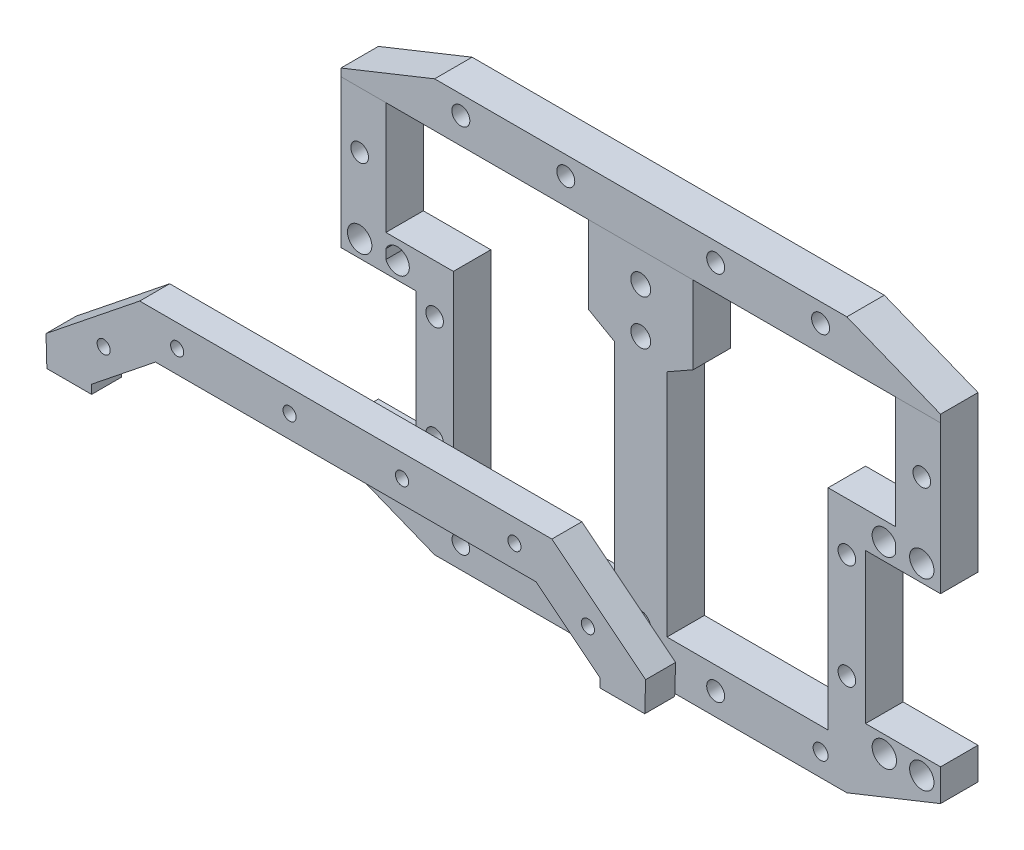
from build123d import *

# Parameters (mm, degrees)
SKETCH1_R           = 2.399612855
SKETCH1_R_2         = 2.65
SKETCH1_R_3         = 2.350999085
SKETCH1_R_4         = 3.25
SKETCH1_R_5         = 2.35
SKETCH1_R_6         = 2
SKETCH1_R_7         = 2.477632292
SKETCH1_R_8         = 2.354161753
BOSS_EXTRUDE1_DEPTH = 10
SKETCH2_R           = 6
SKETCH2_R_2         = 1.75
BOSS_EXTRUDE2_DEPTH = 8
SKETCH3_W           = 243.313173006
SKETCH3_H           = 81.330853515
CUT_EXTRUDE1_DEPTH  = 8
CUT_EXTRUDE2_DEPTH  = 8


with BuildPart() as part:
    # Sketch1 → Boss-Extrude1 (new body)
    with BuildSketch(Plane.XY):
        Polygon((80, -36.5), (60, -36.5), (60, 3.5), (80, 3.5), (80, 45), (55, 55), (-55, 55), (-80, 45), (-80, 3.5), (-60, 3.5), (-60, -36.5), (-80, -36.5), (-80, -45), (-55, -55), (55, -55), (80, -45), align=None)
        with Locations((-48, 50)):
            Circle(SKETCH1_R, mode=Mode.SUBTRACT)
        with Locations((-20, 50)):
            Circle(SKETCH1_R, mode=Mode.SUBTRACT)
        with Locations((0, 35)):
            Circle(SKETCH1_R_2, mode=Mode.SUBTRACT)
        with Locations((0, 23)):
            Circle(SKETCH1_R_2, mode=Mode.SUBTRACT)
        with Locations((20, 50)):
            Circle(SKETCH1_R, mode=Mode.SUBTRACT)
        with Locations((48, 50)):
            Circle(SKETCH1_R, mode=Mode.SUBTRACT)
        with Locations((75, 28)):
            Circle(SKETCH1_R_3, mode=Mode.SUBTRACT)
        with Locations((75, 8)):
            Circle(SKETCH1_R_4, mode=Mode.SUBTRACT)
        with Locations((55, 0)):
            Circle(SKETCH1_R_5, mode=Mode.SUBTRACT)
        with Locations((55, -28)):
            Circle(SKETCH1_R_5, mode=Mode.SUBTRACT)
        with Locations((75, -41)):
            Circle(SKETCH1_R_4, mode=Mode.SUBTRACT)
        with Locations((65, -41)):
            Circle(SKETCH1_R_4, mode=Mode.SUBTRACT)
        with Locations((48, -49)):
            Circle(SKETCH1_R_6, mode=Mode.SUBTRACT)
        with Locations((20, -49)):
            Circle(SKETCH1_R, mode=Mode.SUBTRACT)
        with Locations((0, -43)):
            Circle(SKETCH1_R_2, mode=Mode.SUBTRACT)
        with Locations((-20, -49)):
            Circle(SKETCH1_R_7, mode=Mode.SUBTRACT)
        with Locations((-48, -49)):
            Circle(SKETCH1_R_8, mode=Mode.SUBTRACT)
        with Locations((-75, -41)):
            Circle(SKETCH1_R_4, mode=Mode.SUBTRACT)
        with Locations((-65, -41)):
            Circle(SKETCH1_R_4, mode=Mode.SUBTRACT)
        with Locations((-55, -28)):
            Circle(SKETCH1_R_5, mode=Mode.SUBTRACT)
        with Locations((-55, 0)):
            Circle(SKETCH1_R_5, mode=Mode.SUBTRACT)
        with Locations((-75, 8)):
            Circle(SKETCH1_R_4, mode=Mode.SUBTRACT)
        with Locations((-75, 28)):
            Circle(SKETCH1_R_3, mode=Mode.SUBTRACT)
        with BuildLine():
            Line((68, 6.75), (68, 9.25))
            ThreePointArc((68, 9.25), (61.75, 8), (68, 6.75))
        make_face(mode=Mode.SUBTRACT)
        with BuildLine():
            Line((-68, 6.75), (-68, 9.25))
            ThreePointArc((-68, 9.25), (-61.75, 8), (-68, 6.75))
        make_face(mode=Mode.SUBTRACT)
        Polygon((-50, 13), (-68, 13), (-68, 43), (-14, 43), (-14, 22.26503624), (-7, 18.293621962), (-7, -43), (-50, -43), align=None, mode=Mode.SUBTRACT)
        Polygon((50, -43), (7, -43), (7, 18.293621962), (14, 22.26503624), (14, 43), (68, 43), (68, 13), (50, 13), align=None, mode=Mode.SUBTRACT)
    extrude(amount=BOSS_EXTRUDE1_DEPTH)


with BuildPart() as body_2:
    # Sketch2 → Boss-Extrude2 (new body)
    with BuildSketch(Plane.XY.offset(88.7)):
        Polygon((-80, 22.996033378), (-55, 42.996033378), (55, 42.996033378), (80, 22.996033378), (77.932657225, -48.34767687), (70, -55.003966622), (-70, -55.003966622), (-77.932657225, -48.34767687), align=None)
        with Locations((-70, -27.003966622)):
            Circle(SKETCH2_R, mode=Mode.SUBTRACT)
        with Locations((-45, 36.996033378)):
            Circle(SKETCH2_R_2, mode=Mode.SUBTRACT)
        with Locations((-15, 36.996033378)):
            Circle(SKETCH2_R_2, mode=Mode.SUBTRACT)
        with Locations((-64.608345785, 27.625607665)):
            Circle(SKETCH2_R_2, mode=Mode.SUBTRACT)
        with Locations((-15, -49.003966622)):
            Circle(SKETCH2_R_2, mode=Mode.SUBTRACT)
        with Locations((15, -49.003966622)):
            Circle(SKETCH2_R_2, mode=Mode.SUBTRACT)
        with Locations((64.608345785, 27.625607665)):
            Circle(SKETCH2_R_2, mode=Mode.SUBTRACT)
        with Locations((15, 36.996033378)):
            Circle(SKETCH2_R_2, mode=Mode.SUBTRACT)
        with Locations((45, 36.996033378)):
            Circle(SKETCH2_R_2, mode=Mode.SUBTRACT)
        with Locations((70, -27.003966622)):
            Circle(SKETCH2_R, mode=Mode.SUBTRACT)
        with BuildLine():
            Line((-67.831737509, 17.363145201), (-50.790627288, 30.996033378))
            Line((-50.790627288, 30.996033378), (50.790627288, 30.996033378))
            Line((50.790627288, 30.996033378), (67.831737509, 17.363145201))
            Line((67.831737509, 17.363145201), (67, 14.66))
            Line((67, 14.66), (67, -11.34))
            Line((67, -11.34), (66.741852409, -20.248637298))
            ThreePointArc((66.741852409, -20.248637298), (62.503146817, -26.786728617), (66.356146477, -33.559295103))
            Line((66.356146477, -33.559295103), (66.09368314, -42.616868186))
            Line((66.09368314, -42.616868186), (65.632357189, -43.003966622))
            Line((65.632357189, -43.003966622), (-65.632357189, -43.003966622))
            Line((-65.632357189, -43.003966622), (-66.09368314, -42.616868186))
            Line((-66.09368314, -42.616868186), (-66.356146477, -33.559295103))
            ThreePointArc((-66.356146477, -33.559295103), (-62.503146817, -26.786728617), (-66.741852409, -20.248637298))
            Line((-66.741852409, -20.248637298), (-67, -11.34))
            Line((-67, -11.34), (-67, 14.66))
            Line((-67, 14.66), (-67.831737509, 17.363145201))
        make_face(mode=Mode.SUBTRACT)
    extrude(amount=-BOSS_EXTRUDE2_DEPTH)

    # Sketch3 → Cut-Extrude1 (cut)
    with BuildSketch(Plane.XY.offset(88.7)):
        with Locations((0, -25.66939338)):
            Rectangle(SKETCH3_W, SKETCH3_H)
    extrude(amount=-CUT_EXTRUDE1_DEPTH, mode=Mode.SUBTRACT)

    # Sketch4 → Cut-Extrude2 (cut)
    with BuildSketch(Plane.XY.offset(88.7)):
        Polygon((-67.831737509, 17.363145201), (-67.831737509, 14.996033378), (-67.103394951, 14.996033378), align=None)
        Polygon((67.831737509, 17.363145201), (67.831737509, 14.996033378), (67.103394951, 14.996033378), align=None)
    extrude(amount=-CUT_EXTRUDE2_DEPTH, mode=Mode.SUBTRACT)


solid = Compound([part.part, body_2.part])
